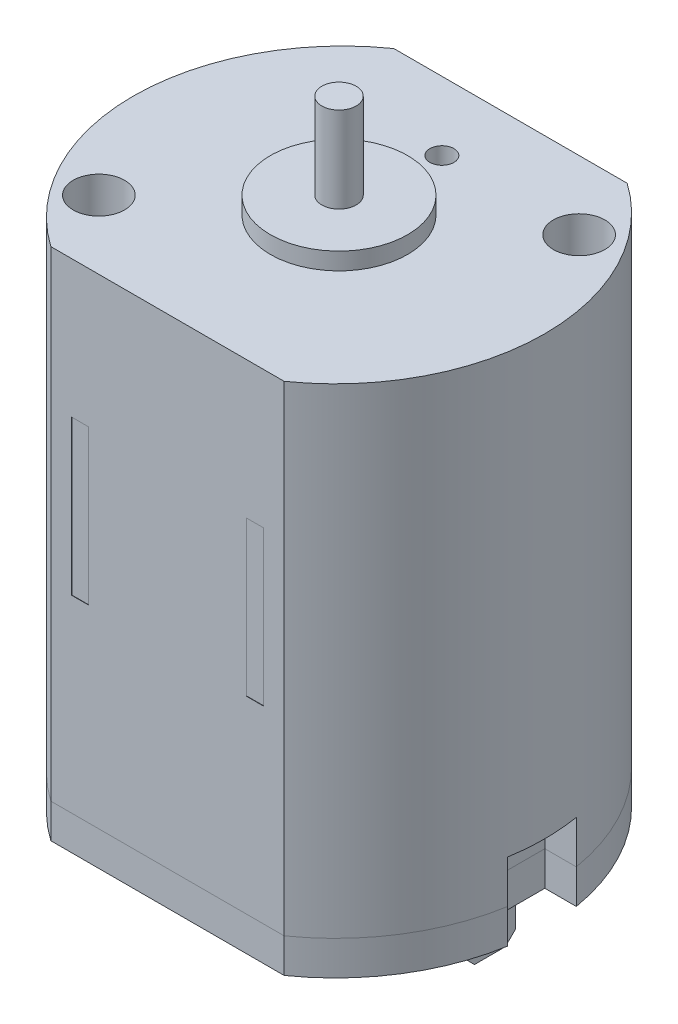
from build123d import *

# Parameters (mm, degrees)
SALIENTE_EXTRUIR1_DEPTH = 1
SALIENTE_EXTRUIR2_DEPTH = 14
CROQUIS3_W              = 0.5
CROQUIS3_H              = 4.5
CORTAR_EXTRUIR1_DEPTH   = 0.01
CORTAR_EXTRUIR2_DEPTH   = 2.25
CROQUIS5_R              = 2.5
SALIENTE_EXTRUIR3_DEPTH = 1
CROQUIS6_R              = 1
CORTAR_EXTRUIR3_DEPTH   = 0.5
CROQUIS7_W              = 0.3
CROQUIS7_H              = 1.5
SALIENTE_EXTRUIR4_DEPTH = 1.5
CROQUIS8_R              = 0.5
CORTAR_EXTRUIR4_DEPTH   = 1
CHAFL_N1_SIZE           = 0.3
CROQUIS9_R              = 0.75
CORTAR_EXTRUIR5_DEPTH   = 0.05
CROQUIS10_R             = 0.25
CORTAR_EXTRUIR6_DEPTH   = 1
CROQUIS11_R             = 0.75
CORTAR_EXTRUIR7_DEPTH   = 0.05
CROQUIS12_R             = 2
SALIENTE_EXTRUIR5_DEPTH = 0.5
CROQUIS13_R             = 0.5
SALIENTE_EXTRUIR6_DEPTH = 2.5
CROQUIS14_R             = 0.75
CROQUIS14_R_2           = 0.35
CORTAR_EXTRUIR8_DEPTH   = 2.5


with BuildPart() as part:
    # Croquis1 → Saliente-Extruir1 (new body)
    with BuildSketch(Plane(origin=(0, 0, 0), x_dir=(1, 0, 0), z_dir=(0, 1, 0))):
        with BuildLine():
            Line((-3.4, 5), (3.4, 5))
            ThreePointArc((3.4, 5), (6, 0), (3.4, -5))
            Line((3.4, -5), (-3.4, -5))
            ThreePointArc((-3.4, -5), (-6, 0), (-3.4, 5))
        make_face()
    extrude(amount=SALIENTE_EXTRUIR1_DEPTH)


with BuildPart() as body_2:
    # Croquis2 → Saliente-Extruir2 (new body)
    with BuildSketch(Plane(origin=(0, 1, 0), x_dir=(1, 0, 0), z_dir=(0, 1, 0))):
        with BuildLine():
            Line((-3.4, 5), (3.4, 5))
            ThreePointArc((3.4, 5), (6, 0), (3.4, -5))
            Line((3.4, -5), (-3.4, -5))
            ThreePointArc((-3.4, -5), (-6, 0), (-3.4, 5))
        make_face()
    extrude(amount=SALIENTE_EXTRUIR2_DEPTH)

    # Croquis3 → Cortar-Extruir1 (cut)
    with BuildSketch(Plane.XY.offset(5)):
        with Locations((-2.55, 8.75)):
            Rectangle(CROQUIS3_W, CROQUIS3_H)
        with Locations((2.55, 8.75)):
            Rectangle(CROQUIS3_W, CROQUIS3_H)
    cortar_extruir1 = extrude(amount=-CORTAR_EXTRUIR1_DEPTH, mode=Mode.SUBTRACT)

    # Simetría2: Cortar-Extruir1 across plane
    add(cortar_extruir1.mirror(Plane.XY), mode=Mode.SUBTRACT)


with BuildPart() as cortar_extruir2_tool:
    # Croquis4 → Cortar-Extruir2 (new body)
    with BuildSketch(Plane.XZ):
        with BuildLine():
            Line((5, 1), (5, -1))
            Line((5, -1), (5.917579912, -1))
            ThreePointArc((5.917579912, -1), (6, 0), (5.917579912, 1))
            Line((5.917579912, 1), (5, 1))
        make_face()
        with BuildLine():
            Line((-5, 1), (-5.917579912, 1))
            ThreePointArc((-5.917579912, 1), (-6, 0), (-5.917579912, -1))
            Line((-5.917579912, -1), (-5, -1))
            Line((-5, -1), (-5, 1))
        make_face()
    extrude(amount=-CORTAR_EXTRUIR2_DEPTH)


with BuildPart() as part_1:
    add(part.part)

    # Cortar-Extruir2: cut by cortar_extruir2_tool
    add(cortar_extruir2_tool.part, mode=Mode.SUBTRACT)

    # Croquis5 → Saliente-Extruir3 (add)
    with BuildSketch(Plane.XZ):
        Circle(CROQUIS5_R)
    extrude(amount=SALIENTE_EXTRUIR3_DEPTH)

    # Croquis6 → Cortar-Extruir3 (cut)
    with BuildSketch(Plane.XZ.offset(1)):
        Circle(CROQUIS6_R)
    extrude(amount=-CORTAR_EXTRUIR3_DEPTH, mode=Mode.SUBTRACT)

    # Croquis7 → Saliente-Extruir4 (add)
    with BuildSketch(Plane.XZ):
        with Locations((4.25, 0)):
            Rectangle(CROQUIS7_W, CROQUIS7_H)
        with Locations((-4.25, 0)):
            Rectangle(CROQUIS7_W, CROQUIS7_H)
    extrude(amount=SALIENTE_EXTRUIR4_DEPTH)

    # Croquis8 → Cortar-Extruir4 (cut)
    with BuildSketch(Plane(origin=(4.4, 0, 0), x_dir=(0, 0, -1), z_dir=(1, 0, 0))):
        with Locations((0, -0.75)):
            Circle(CROQUIS8_R)
    cortar_extruir4 = extrude(amount=-CORTAR_EXTRUIR4_DEPTH, mode=Mode.SUBTRACT)

    # Simetría3: Cortar-Extruir4 across plane
    add(cortar_extruir4.mirror(Plane(origin=(0, 0, 0), x_dir=(0, 0, 1), z_dir=(1, 0, 0))), mode=Mode.SUBTRACT)

    # Chaflán1
    chafl_n1_edges = [part_1.edges().sort_by_distance(p)[0] for p in [
        (4.25, -1.5, 0.75),
        (4.25, -1.5, -0.75),
        (-4.25, -1.5, 0.75),
        (-4.25, -1.5, -0.75),
    ]]
    chamfer(chafl_n1_edges, length=CHAFL_N1_SIZE)

    # Croquis9 → Cortar-Extruir5 (cut)
    with BuildSketch(Plane.XZ):
        with Locations((2.689144547, 3.086404537)):
            Circle(CROQUIS9_R)
        with Locations((0, -3.660903599)):
            Circle(CROQUIS9_R)
    extrude(amount=-CORTAR_EXTRUIR5_DEPTH, mode=Mode.SUBTRACT)


with BuildPart() as body_2_1:
    add(body_2.part)

    # Cortar-Extruir2: cut by cortar_extruir2_tool
    add(cortar_extruir2_tool.part, mode=Mode.SUBTRACT)


with BuildPart() as cortar_extruir6_tool:
    # Croquis10 → Cortar-Extruir6 (new body)
    with BuildSketch(Plane.XZ.offset(-0.05)):
        with Locations((2.689144547, 3.086404537)):
            Circle(CROQUIS10_R)
    extrude(amount=-CORTAR_EXTRUIR6_DEPTH)


with BuildPart() as part_2:
    add(part_1.part)

    # Cortar-Extruir6: cut by cortar_extruir6_tool
    add(cortar_extruir6_tool.part, mode=Mode.SUBTRACT)

    # Croquis11 → Cortar-Extruir7 (cut)
    with BuildSketch(Plane.XZ):
        with Locations((-2.687365336, 3.086404537)):
            Circle(CROQUIS11_R)
        with BuildLine():
            Line((-2.637365336, 3.794778488), (-2.637365336, 3.136404537))
            Line((-2.637365336, 3.136404537), (-1.97177306, 3.136404537))
            ThreePointArc((-1.97177306, 3.136404537), (-1.970028382, 3.086404537), (-1.97177306, 3.036404537))
            Line((-1.97177306, 3.036404537), (-2.637365336, 3.036404537))
            Line((-2.637365336, 3.036404537), (-2.637365336, 2.378030586))
            Line((-2.637365336, 2.378030586), (-2.637365336, 2.370812261))
            ThreePointArc((-2.637365336, 2.370812261), (-2.687365336, 2.369067583), (-2.737365336, 2.370812261))
            Line((-2.737365336, 2.370812261), (-2.737365336, 2.378030586))
            Line((-2.737365336, 2.378030586), (-2.737365336, 3.036404537))
            Line((-2.737365336, 3.036404537), (-3.402957612, 3.036404537))
            ThreePointArc((-3.402957612, 3.036404537), (-3.40470229, 3.086404537), (-3.402957612, 3.136404537))
            Line((-3.402957612, 3.136404537), (-2.737365336, 3.136404537))
            Line((-2.737365336, 3.136404537), (-2.737365336, 3.794778488))
            Line((-2.737365336, 3.794778488), (-2.737365336, 3.801996813))
            ThreePointArc((-2.737365336, 3.801996813), (-2.687365336, 3.803741491), (-2.637365336, 3.801996813))
            Line((-2.637365336, 3.801996813), (-2.637365336, 3.794778488))
        make_face(mode=Mode.SUBTRACT)
    extrude(amount=-CORTAR_EXTRUIR7_DEPTH, mode=Mode.SUBTRACT)


with BuildPart() as body_2_2:
    add(body_2_1.part)

    # Cortar-Extruir6: cut by cortar_extruir6_tool
    add(cortar_extruir6_tool.part, mode=Mode.SUBTRACT)

    # Croquis14 → Cortar-Extruir8 (cut)
    with BuildSketch(Plane(origin=(0, 15, 0), x_dir=(1, 0, 0), z_dir=(0, 1, 0))):
        with Locations((-4, -3)):
            Circle(CROQUIS14_R)
        with Locations((4, 3)):
            Circle(CROQUIS14_R)
        with Locations((0, 3)):
            Circle(CROQUIS14_R_2)
    extrude(amount=-CORTAR_EXTRUIR8_DEPTH, mode=Mode.SUBTRACT)


with BuildPart() as body_3:
    # Croquis12 → Saliente-Extruir5 (new body)
    with BuildSketch(Plane(origin=(0, 15, 0), x_dir=(1, 0, 0), z_dir=(0, 1, 0))):
        Circle(CROQUIS12_R)
    extrude(amount=SALIENTE_EXTRUIR5_DEPTH)


with BuildPart() as body_4:
    # Croquis13 → Saliente-Extruir6 (new body)
    with BuildSketch(Plane(origin=(0, 15.5, 0), x_dir=(1, 0, 0), z_dir=(0, 1, 0))):
        Circle(CROQUIS13_R)
    extrude(amount=SALIENTE_EXTRUIR6_DEPTH)


solid = Compound([part_2.part, body_2_2.part, body_3.part, body_4.part])
